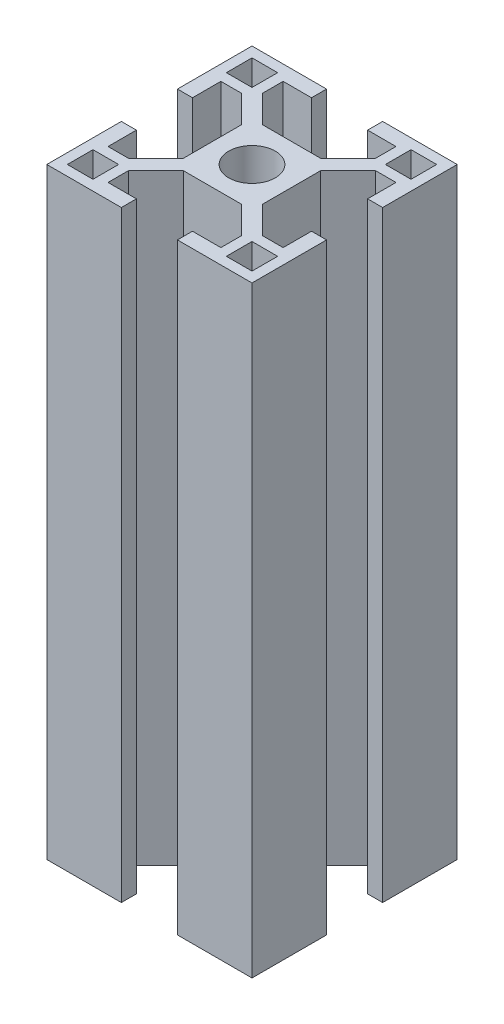
from build123d import *

# Parameters (mm, degrees)
SZKIC1_R                    = 3.4
SZKIC1_W                    = 3.75
SZKIC1_H                    = 3.75
DODANIE_WYCI_GNI_CIE1_DEPTH = 88


with BuildPart() as part:
    # Szkic1 → Dodanie-wyciągnięcie1 (new body)
    with BuildSketch(Plane(origin=(0, 0, 0), x_dir=(1, 0, 0), z_dir=(0, 1, 0))):
        Polygon((4.1, 15), (4.1, 12.8), (8.25, 12.8), (8.25, 9.805634919), (4.244365081, 5.8), (-4.244365081, 5.8), (-8.25, 9.805634919), (-8.25, 12.8), (-4.1, 12.8), (-4.1, 15), (-15, 15), (-15, 4.1), (-12.8, 4.1), (-12.8, 8.25), (-9.805634919, 8.25), (-5.8, 4.244365081), (-5.8, -4.244365081), (-9.805634919, -8.25), (-12.8, -8.25), (-12.8, -4.1), (-15, -4.1), (-15, -15), (-4.1, -15), (-4.1, -12.8), (-8.25, -12.8), (-8.25, -9.805634919), (-4.244365081, -5.8), (4.244365081, -5.8), (8.25, -9.805634919), (8.25, -12.8), (4.1, -12.8), (4.1, -15), (15, -15), (15, -4.1), (12.8, -4.1), (12.8, -8.25), (9.805634919, -8.25), (5.8, -4.244365081), (5.8, 4.244365081), (9.805634919, 8.25), (12.8, 8.25), (12.8, 4.1), (15, 4.1), (15, 15), align=None)
        Circle(SZKIC1_R, mode=Mode.SUBTRACT)
        with Locations((11.625, 11.625)):
            Rectangle(SZKIC1_W, SZKIC1_H, mode=Mode.SUBTRACT)
        with Locations((11.625, -11.625)):
            Rectangle(SZKIC1_W, SZKIC1_H, mode=Mode.SUBTRACT)
        with Locations((-11.625, -11.625)):
            Rectangle(SZKIC1_W, SZKIC1_H, mode=Mode.SUBTRACT)
        with Locations((-11.625, 11.625)):
            Rectangle(SZKIC1_W, SZKIC1_H, mode=Mode.SUBTRACT)
    extrude(amount=DODANIE_WYCI_GNI_CIE1_DEPTH)


solid = part.part
